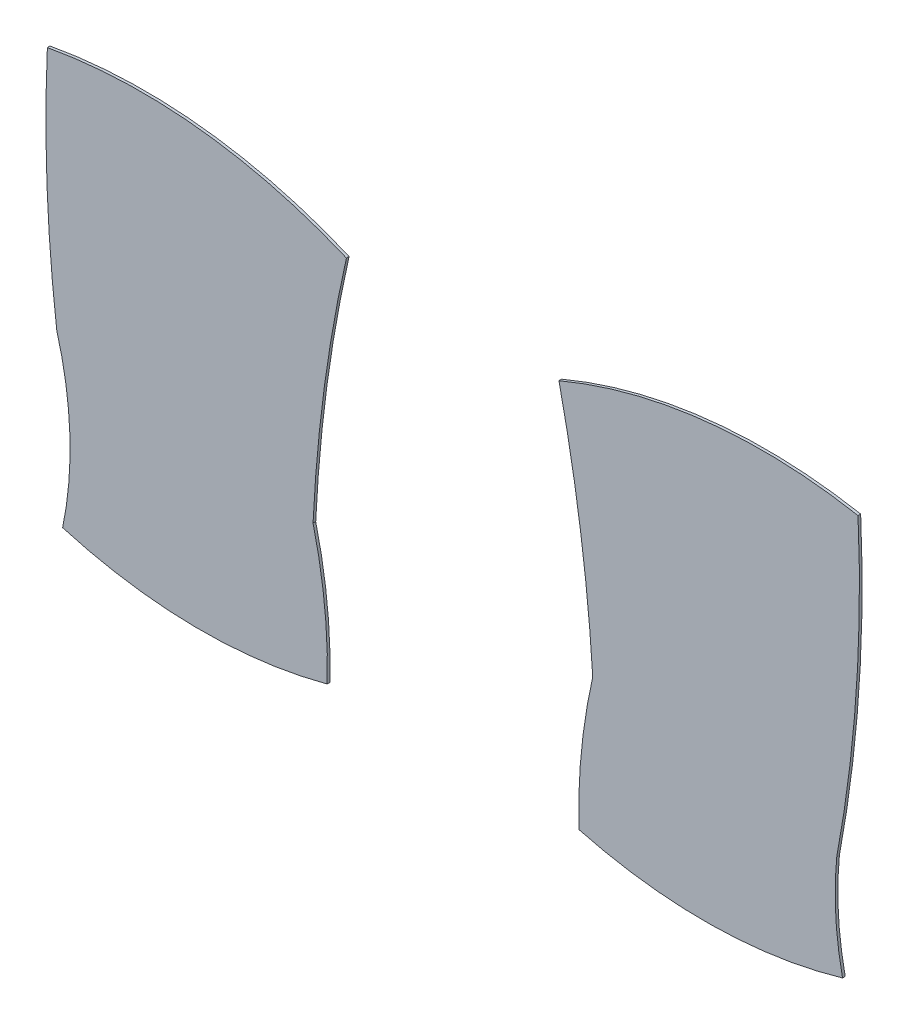
from build123d import *

# Parameters (mm, degrees)
SALIENTE_EXTRUIR1_DEPTH   = 0.1
SALIENTE_EXTRUIR1_2_DEPTH = 0.1


with BuildPart() as part:
    # Model → Saliente-Extruir1 (new body)
    with BuildSketch(Plane.XY):
        with BuildLine():
            ThreePointArc((38.727641792, 40.830951587), (38.715344206, 36.29551839), (39.082639899, 31.774965394))
            ThreePointArc((39.082639899, 31.774965394), (39.576436382, 28.626551083), (39.303879403, 25.451325054))
            ThreePointArc((39.303879403, 25.451325054), (44.279831034, 24.708477296), (49.271920409, 25.333746117))
            ThreePointArc((49.271920409, 25.333746117), (49.17471595, 27.843656594), (48.738802888, 30.317333838))
            ThreePointArc((48.738802888, 30.317333838), (49.164023548, 34.985180658), (49.996422938, 39.597849929))
            ThreePointArc((49.996422938, 39.597849929), (44.452398712, 41.040219605), (38.727641792, 40.830951587))
        make_face()
    extrude(amount=SALIENTE_EXTRUIR1_DEPTH)


with BuildPart() as body_2:
    # Model → Saliente-Extruir1 2 (new body)
    with BuildSketch(Plane.XY):
        with BuildLine():
            ThreePointArc((59.277255482, 30.565564579), (58.817484117, 35.106939847), (58.003885533, 39.598435853))
            ThreePointArc((58.003885533, 39.598435853), (63.547698616, 41.041616851), (69.272486101, 40.833186622))
            ThreePointArc((69.272486101, 40.833186622), (69.205973765, 35.03683073), (68.469937989, 29.287011876))
            ThreePointArc((68.469937989, 29.287011876), (68.431410818, 27.360007199), (68.690596183, 25.450123875))
            ThreePointArc((68.690596183, 25.450123875), (63.728868303, 24.708599385), (58.750350145, 25.327436261))
            ThreePointArc((58.750350145, 25.327436261), (58.852313973, 27.962744644), (59.277255482, 30.565564579))
        make_face()
    extrude(amount=SALIENTE_EXTRUIR1_2_DEPTH)


solid = Compound([part.part, body_2.part])
